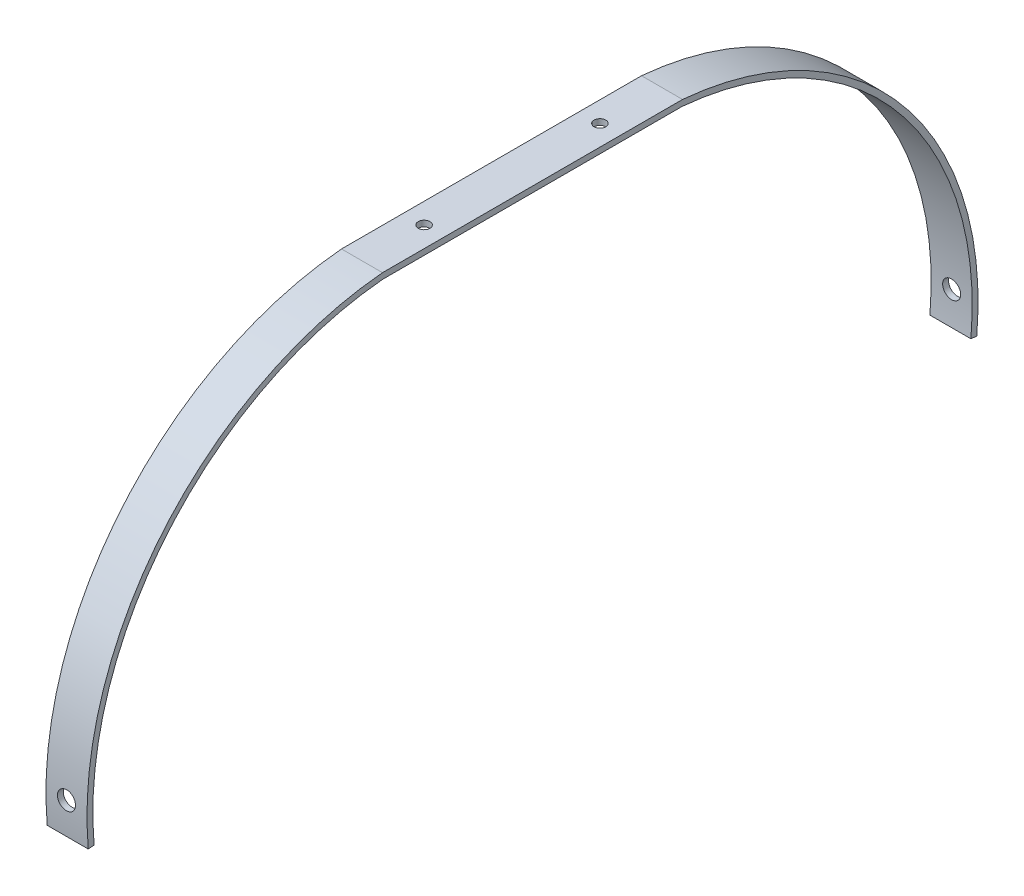
from build123d import *

# Parameters (mm, degrees)
BOSS_EXTRUDE1_DEPTH     = 17.78
SKETCH2_R               = 3.914165929
CUT_EXTRUDE1_DEPTH      = 194.058628532
CUT_EXTRUDE1_DEPTH_BACK = 194.058628532
SKETCH3_R               = 2.54
CUT_EXTRUDE2_DEPTH      = 7.62


with BuildPart() as part:
    # Sketch1 → Boss-Extrude1 (new body)
    with BuildSketch(Plane(origin=(0, 0, 0), x_dir=(0, 0, -1), z_dir=(1, 0, 0))):
        with BuildLine():
            Line((65, 1.27), (-65, 1.27))
            ThreePointArc((-65, 1.27), (-160.342068402, -48.593885399), (-192.5, -151.27))
            Line((-192.5, -151.27), (-189.970093401, -151.043786383))
            ThreePointArc((-189.970093401, -151.043786383), (-158.429364067, -50.266130166), (-64.886150372, -1.27))
            Line((-64.886150372, -1.27), (64.886150372, -1.27))
            ThreePointArc((64.886150372, -1.27), (158.429364067, -50.266130166), (189.970093401, -151.043786383))
            Line((189.970093401, -151.043786383), (192.5, -151.27))
            ThreePointArc((192.5, -151.27), (160.342068402, -48.593885399), (65, 1.27))
        make_face()
    extrude(amount=BOSS_EXTRUDE1_DEPTH)

    # Sketch2 → Cut-Extrude1 (cut, two sides)
    with BuildSketch(Plane.XY) as cut_extrude1_sk:
        with Locations((8.89, -137.16)):
            Circle(SKETCH2_R)
    extrude(amount=CUT_EXTRUDE1_DEPTH, mode=Mode.SUBTRACT)
    extrude(cut_extrude1_sk.sketch, amount=-CUT_EXTRUDE1_DEPTH_BACK, mode=Mode.SUBTRACT)

    # Sketch3 → Cut-Extrude2 (cut)
    with BuildSketch(Plane(origin=(0, 1.27, 0), x_dir=(1, 0, 0), z_dir=(0, 1, 0))):
        with Locations((8.89, 38.1)):
            Circle(SKETCH3_R)
        with Locations((8.89, -38.1)):
            Circle(SKETCH3_R)
    extrude(amount=-CUT_EXTRUDE2_DEPTH, mode=Mode.SUBTRACT)


solid = part.part
